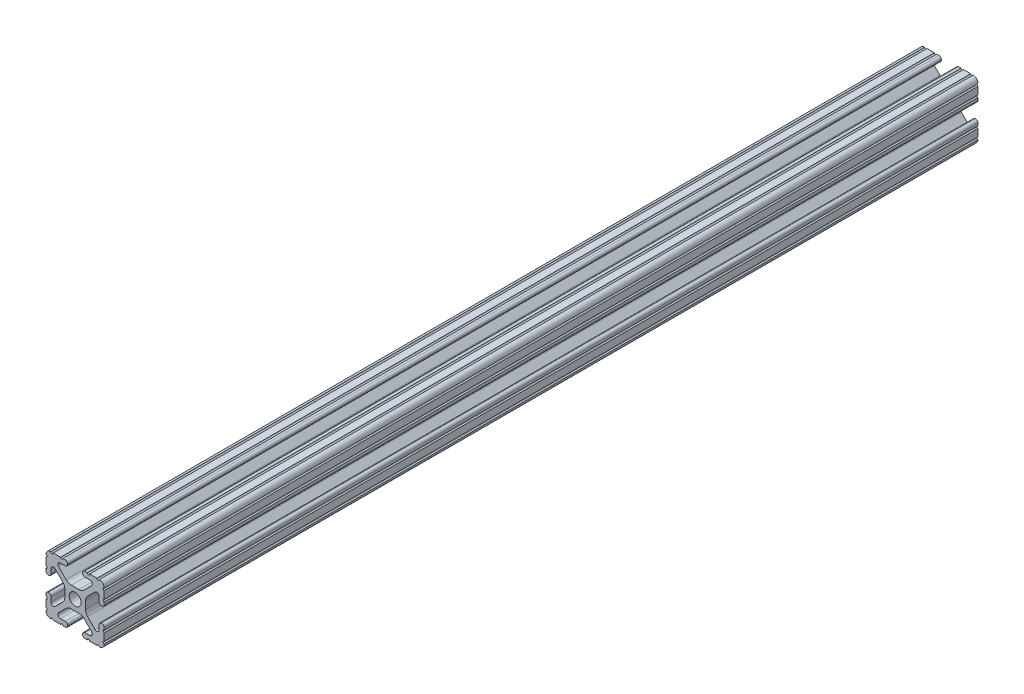
from build123d import *

# Parameters (mm, degrees)
SKETCH1_R           = 2.6035
BOSS_EXTRUDE1_DEPTH = 190.5


with BuildPart() as part:
    # Sketch1 → Boss-Extrude1 (new body, symmetric)
    with BuildSketch(Plane.XY):
        with BuildLine():
            Line((-7.179650497, -8.645192506), (-3.952270251, -5.423690499))
            ThreePointArc((-3.952270251, -5.423690499), (-2.922936451, -4.736929036), (-1.709253557, -4.4958))
            Line((-1.709253557, -4.4958), (1.709253557, -4.4958))
            ThreePointArc((1.709253557, -4.4958), (2.922936451, -4.736929036), (3.952270251, -5.423690499))
            Line((3.952270251, -5.423690499), (7.179650497, -8.645192506))
            ThreePointArc((7.179650497, -8.645192506), (7.41473083, -9.822813117), (6.416408329, -10.4902))
            Line((6.416408329, -10.4902), (4.287512407, -10.4902))
            ThreePointArc((4.287512407, -10.4902), (3.54574862, -10.79744862), (3.2385, -11.539212407))
            Line((3.2385, -11.539212407), (3.2385, -11.650987593))
            ThreePointArc((3.2385, -11.650987593), (3.54574862, -12.39275138), (4.287512407, -12.7))
            Line((4.287512407, -12.7), (5.317126718, -12.7))
            ThreePointArc((5.317126718, -12.7), (5.825126718, -12.192), (6.333126718, -12.7))
            Line((6.333126718, -12.7), (9.550443118, -12.7))
            ThreePointArc((9.550443118, -12.7), (10.058366869, -12.192000006), (10.566443095, -12.699847501))
            ThreePointArc((10.566443095, -12.699847501), (12.082537762, -12.08250727), (12.699846982, -10.566399977))
            ThreePointArc((12.699846982, -10.566399977), (12.192000006, -10.058323491), (12.7, -9.5504))
            Line((12.7, -9.5504), (12.7, -6.3330836))
            ThreePointArc((12.7, -6.3330836), (12.192, -5.8250836), (12.7, -5.3170836))
            Line((12.7, -5.3170836), (12.7, -4.287469289))
            ThreePointArc((12.7, -4.287469289), (12.39275138, -3.545705502), (11.650987593, -3.238456882))
            Line((11.650987593, -3.238456882), (11.539212407, -3.238456882))
            ThreePointArc((11.539212407, -3.238456882), (10.79744862, -3.545705502), (10.4902, -4.287469289))
            Line((10.4902, -4.287469289), (10.4902, -6.402089023))
            ThreePointArc((10.4902, -6.402089023), (9.856505071, -7.351067942), (8.737131347, -7.129408934))
            Line((8.737131347, -7.129408934), (5.441005833, -3.840816462))
            ThreePointArc((5.441005833, -3.840816462), (4.750877967, -2.809883091), (4.5085, -1.593185507))
            Line((4.5085, -1.593185507), (4.5085, 1.593185507))
            ThreePointArc((4.5085, 1.593185507), (4.750877967, 2.809883091), (5.441005833, 3.840816462))
            Line((5.441005833, 3.840816462), (8.737131347, 7.129408934))
            ThreePointArc((8.737131347, 7.129408934), (9.856505071, 7.351067942), (10.4902, 6.402089023))
            Line((10.4902, 6.402089023), (10.4902, 4.287469289))
            ThreePointArc((10.4902, 4.287469289), (10.79744862, 3.545705502), (11.539212407, 3.238456882))
            Line((11.539212407, 3.238456882), (11.650987593, 3.238456882))
            ThreePointArc((11.650987593, 3.238456882), (12.39275138, 3.545705502), (12.7, 4.287469289))
            Line((12.7, 4.287469289), (12.7, 5.3170836))
            ThreePointArc((12.7, 5.3170836), (12.192, 5.8250836), (12.7, 6.3330836))
            Line((12.7, 6.3330836), (12.7, 9.5504))
            ThreePointArc((12.7, 9.5504), (12.192000006, 10.058323491), (12.699846982, 10.566399977))
            ThreePointArc((12.699846982, 10.566399977), (12.082537762, 12.08250727), (10.566443095, 12.699847501))
            ThreePointArc((10.566443095, 12.699847501), (10.058366869, 12.192000006), (9.550443118, 12.7))
            Line((9.550443118, 12.7), (6.333126718, 12.7))
            ThreePointArc((6.333126718, 12.7), (5.825126718, 12.192), (5.317126718, 12.7))
            Line((5.317126718, 12.7), (4.287512407, 12.7))
            ThreePointArc((4.287512407, 12.7), (3.54574862, 12.39275138), (3.2385, 11.650987593))
            Line((3.2385, 11.650987593), (3.2385, 11.539212407))
            ThreePointArc((3.2385, 11.539212407), (3.54574862, 10.79744862), (4.287512407, 10.4902))
            Line((4.287512407, 10.4902), (6.476788598, 10.4902))
            ThreePointArc((6.476788598, 10.4902), (7.432222385, 9.85140422), (7.207036008, 8.724370562))
            Line((7.207036008, 8.724370562), (3.898272566, 5.423169045))
            ThreePointArc((3.898272566, 5.423169045), (2.869120213, 4.736787962), (1.655778399, 4.4958))
            Line((1.655778399, 4.4958), (-1.655778399, 4.4958))
            ThreePointArc((-1.655778399, 4.4958), (-2.869120213, 4.736787962), (-3.898272566, 5.423169045))
            Line((-3.898272566, 5.423169045), (-7.207036008, 8.724370562))
            ThreePointArc((-7.207036008, 8.724370562), (-7.432222385, 9.85140422), (-6.476788598, 10.4902))
            Line((-6.476788598, 10.4902), (-4.287512407, 10.4902))
            ThreePointArc((-4.287512407, 10.4902), (-3.54574862, 10.79744862), (-3.2385, 11.539212407))
            Line((-3.2385, 11.539212407), (-3.2385, 11.650987593))
            ThreePointArc((-3.2385, 11.650987593), (-3.54574862, 12.39275138), (-4.287512407, 12.7))
            Line((-4.287512407, 12.7), (-5.317126718, 12.7))
            ThreePointArc((-5.317126718, 12.7), (-5.825126718, 12.192), (-6.333126718, 12.7))
            Line((-6.333126718, 12.7), (-9.550443118, 12.7))
            ThreePointArc((-9.550443118, 12.7), (-10.058366869, 12.192000006), (-10.566443095, 12.699847501))
            ThreePointArc((-10.566443095, 12.699847501), (-12.082537762, 12.08250727), (-12.699846982, 10.566399977))
            ThreePointArc((-12.699846982, 10.566399977), (-12.192000006, 10.058323491), (-12.7, 9.5504))
            Line((-12.7, 9.5504), (-12.7, 6.3330836))
            ThreePointArc((-12.7, 6.3330836), (-12.192, 5.8250836), (-12.7, 5.3170836))
            Line((-12.7, 5.3170836), (-12.7, 4.287469289))
            ThreePointArc((-12.7, 4.287469289), (-12.39275138, 3.545705502), (-11.650987593, 3.238456882))
            Line((-11.650987593, 3.238456882), (-11.539212407, 3.238456882))
            ThreePointArc((-11.539212407, 3.238456882), (-10.79744862, 3.545705502), (-10.4902, 4.287469289))
            Line((-10.4902, 4.287469289), (-10.4902, 6.402089023))
            ThreePointArc((-10.4902, 6.402089023), (-9.856505071, 7.351067942), (-8.737131347, 7.129408934))
            Line((-8.737131347, 7.129408934), (-5.441005833, 3.840816462))
            ThreePointArc((-5.441005833, 3.840816462), (-4.750877967, 2.809883091), (-4.5085, 1.593185507))
            Line((-4.5085, 1.593185507), (-4.5085, -1.593185507))
            ThreePointArc((-4.5085, -1.593185507), (-4.750877967, -2.809883091), (-5.441005833, -3.840816462))
            Line((-5.441005833, -3.840816462), (-8.737131347, -7.129408934))
            ThreePointArc((-8.737131347, -7.129408934), (-9.856505071, -7.351067942), (-10.4902, -6.402089023))
            Line((-10.4902, -6.402089023), (-10.4902, -4.287469289))
            ThreePointArc((-10.4902, -4.287469289), (-10.79744862, -3.545705502), (-11.539212407, -3.238456882))
            Line((-11.539212407, -3.238456882), (-11.650987593, -3.238456882))
            ThreePointArc((-11.650987593, -3.238456882), (-12.39275138, -3.545705502), (-12.7, -4.287469289))
            Line((-12.7, -4.287469289), (-12.7, -5.3170836))
            ThreePointArc((-12.7, -5.3170836), (-12.192, -5.8250836), (-12.7, -6.3330836))
            Line((-12.7, -6.3330836), (-12.7, -9.5504))
            ThreePointArc((-12.7, -9.5504), (-12.192000006, -10.058323491), (-12.699846982, -10.566399977))
            ThreePointArc((-12.699846982, -10.566399977), (-12.082537762, -12.08250727), (-10.566443095, -12.699847501))
            ThreePointArc((-10.566443095, -12.699847501), (-10.058366869, -12.192000006), (-9.550443118, -12.7))
            Line((-9.550443118, -12.7), (-6.333126718, -12.7))
            ThreePointArc((-6.333126718, -12.7), (-5.825126718, -12.192), (-5.317126718, -12.7))
            Line((-5.317126718, -12.7), (-4.287512407, -12.7))
            ThreePointArc((-4.287512407, -12.7), (-3.54574862, -12.39275138), (-3.2385, -11.650987593))
            Line((-3.2385, -11.650987593), (-3.2385, -11.539212407))
            ThreePointArc((-3.2385, -11.539212407), (-3.54574862, -10.79744862), (-4.287512407, -10.4902))
            Line((-4.287512407, -10.4902), (-6.416408329, -10.4902))
            ThreePointArc((-6.416408329, -10.4902), (-7.41473083, -9.822813117), (-7.179650497, -8.645192506))
        make_face()
        Circle(SKETCH1_R, mode=Mode.SUBTRACT)
    extrude(amount=BOSS_EXTRUDE1_DEPTH, both=True)


solid = part.part
